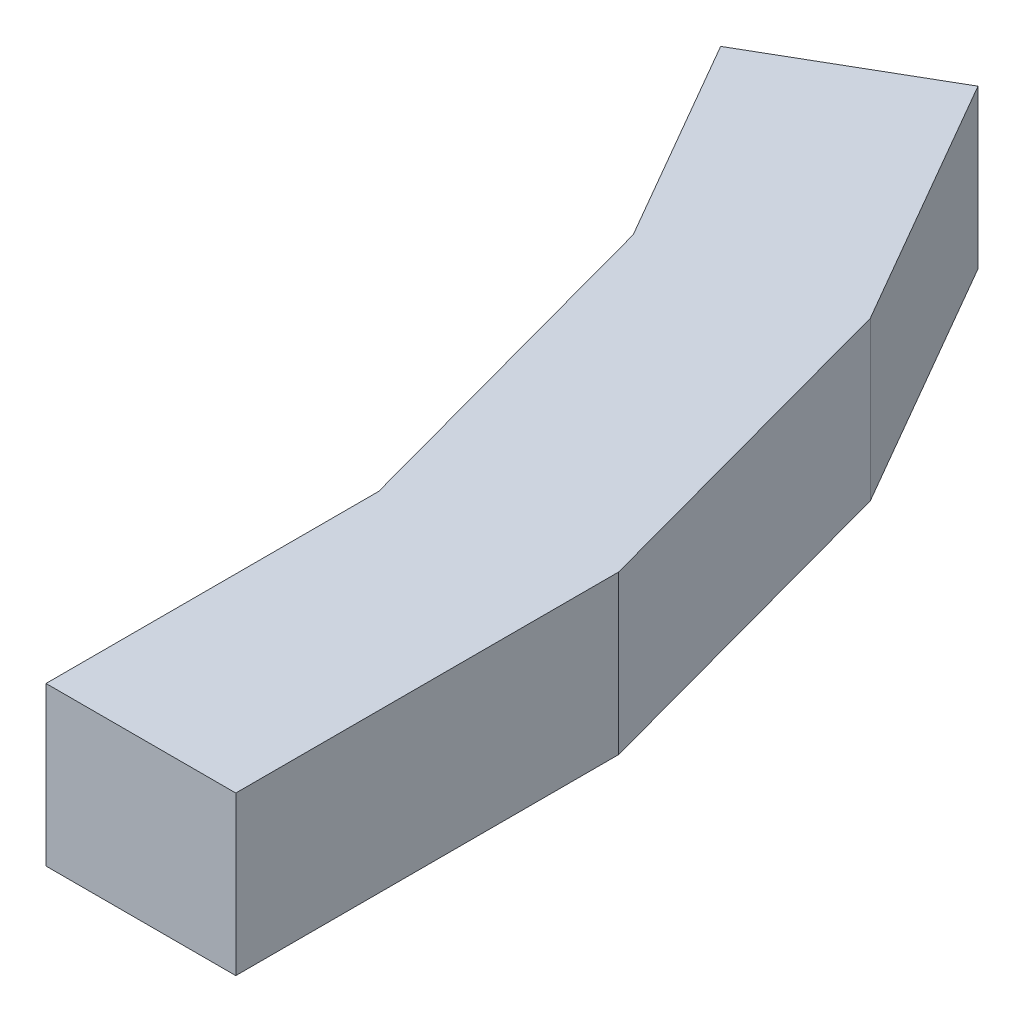
from build123d import *

# Parameters (mm, degrees)
BOSS_EXTRUDE1_DEPTH = 500
BOSS_EXTRUDE2_DEPTH = 500


with BuildPart() as part:
    # Sketch1 → Boss-Extrude1 (new body)
    with BuildSketch(Plane(origin=(0, 0, 0), x_dir=(1, 0, 0), z_dir=(0, 1, 0))):
        Polygon((-479.010759858, 1464.647663661), (-101.47714403, 810.74025948), (502.083882717, 956.5813546), (36.811056846, 1762.457528389), align=None)
    extrude(amount=BOSS_EXTRUDE1_DEPTH)

    # Sketch1_3 → Boss-Extrude2 (add)
    with BuildSketch(Plane(origin=(0, 0, 0), x_dir=(1, 0, 0), z_dir=(0, 1, 0))):
        Polygon((798.89792549, -1346.189835627), (798.89792549, -135.512175948), (502.083882717, 956.5813546), (-101.47714403, 810.74025948), (198.89792549, -294.455664187), (198.89792549, -1346.189835627), align=None)
    extrude(amount=BOSS_EXTRUDE2_DEPTH)


solid = part.part
